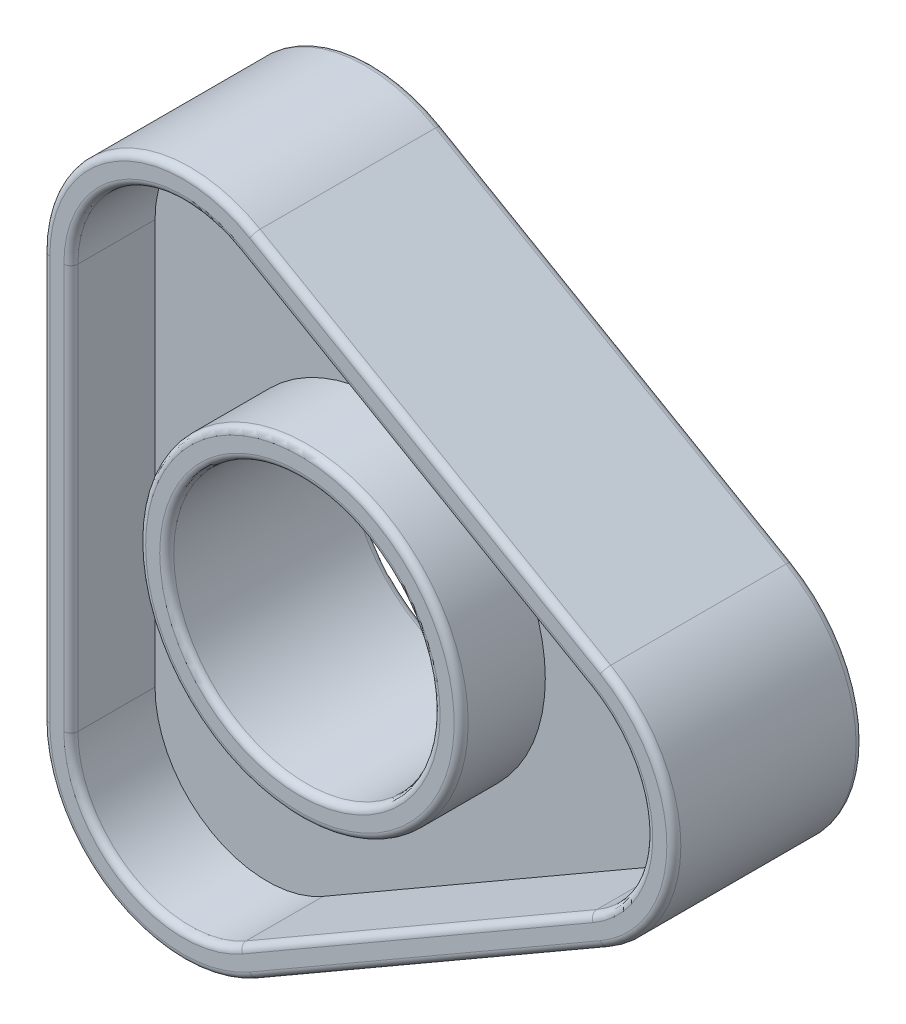
from build123d import *

# Parameters (mm, degrees)
EXTRUDE_1_DEPTH     = 13.5
CUT_EXTRUDE_1_DEPTH = 6
CUT_EXTRUDE_2_DEPTH = 6
EXTRUDE_START       = -7.5
SKETCH_4_R          = 11.5
EXTRUDE_2_DEPTH     = 13.5
CUT_EXTRUDE_3_REACH = 15.5
SKETCH_5_R          = 9.5
FILLET_1_R          = 0.5


with BuildPart() as part:
    # 草圖1 → 填料-伸長1 (new body)
    with BuildSketch(Plane.XY):
        with BuildLine():
            Line((21.666666667, 8.660254038), (-3.333333333, 23.094010768))
            ThreePointArc((-3.333333333, 23.094010768), (-13.333333333, 23.094010768), (-18.333333333, 14.43375673))
            Line((-18.333333333, 14.43375673), (-18.333333333, -14.43375673))
            ThreePointArc((-18.333333333, -14.43375673), (-13.333333333, -23.094010768), (-3.333333333, -23.094010768))
            Line((-3.333333333, -23.094010768), (21.666666667, -8.660254038))
            ThreePointArc((21.666666667, -8.660254038), (26.666666667, 0), (21.666666667, 8.660254038))
        make_face()
    extrude(amount=EXTRUDE_1_DEPTH)

    # 草圖2 → 除料-伸長1 (cut)
    with BuildSketch(Plane.XY.offset(13.5)):
        with BuildLine():
            Line((20.666666667, 6.92820323), (-4.333333333, 21.36195996))
            ThreePointArc((-4.333333333, 21.36195996), (-12.333333333, 21.36195996), (-16.333333333, 14.43375673))
            Line((-16.333333333, 14.43375673), (-16.333333333, -14.43375673))
            ThreePointArc((-16.333333333, -14.43375673), (-12.333333333, -21.36195996), (-4.333333333, -21.36195996))
            Line((-4.333333333, -21.36195996), (20.666666667, -6.92820323))
            ThreePointArc((20.666666667, -6.92820323), (24.666666667, 0), (20.666666667, 6.92820323))
        make_face()
    extrude(amount=-CUT_EXTRUDE_1_DEPTH, mode=Mode.SUBTRACT)

    # 草圖3 → 除料-伸長2 (cut)
    with BuildSketch(Plane(origin=(0, 0, 0), x_dir=(-1, 0, 0), z_dir=(0, 0, -1))):
        with BuildLine():
            Line((-20.666666667, -6.92820323), (4.333333333, -21.36195996))
            ThreePointArc((4.333333333, -21.36195996), (12.333333333, -21.36195996), (16.333333333, -14.43375673))
            Line((16.333333333, -14.43375673), (16.333333333, 14.43375673))
            ThreePointArc((16.333333333, 14.43375673), (12.333333333, 21.36195996), (4.333333333, 21.36195996))
            Line((4.333333333, 21.36195996), (-20.666666667, 6.92820323))
            ThreePointArc((-20.666666667, 6.92820323), (-24.666666667, 0), (-20.666666667, -6.92820323))
        make_face()
    extrude(amount=-CUT_EXTRUDE_2_DEPTH, mode=Mode.SUBTRACT)

    # 草圖4 → 填料-伸長2 (add)
    with BuildSketch(Plane.XY.offset(7.5).offset(EXTRUDE_START)):
        Circle(SKETCH_4_R)
    extrude(amount=EXTRUDE_2_DEPTH)

    # 草圖5 → 除料-伸長3 (cut, up to next)
    with BuildSketch(Plane.XY.offset(13.5), mode=Mode.PRIVATE) as cut_extrude_3_sk1:
        Circle(SKETCH_5_R)
    cut_extrude_3_tool1 = extrude(cut_extrude_3_sk1.sketch, amount=-CUT_EXTRUDE_3_REACH, mode=Mode.PRIVATE) & part.part
    add(cut_extrude_3_tool1.solids().sort_by_distance((0, 0, 13.5))[0], mode=Mode.SUBTRACT)

    # 圓角1
    fillet_1_edges = [part.edges().sort_by_distance(p)[0] for p in [
        (-13.333333333, 23.094010768, 13.5),
        (-18.333333333, 0, 13.5),
        (-13.333333333, -23.094010768, 13.5),
        (24.666666667, 0, 13.5),
        (9.166666667, -15.877132403, 13.5),
        (8.166666667, 14.145081595, 13.5),
        (-12.333333333, 21.36195996, 13.5),
        (-16.333333333, 0, 13.5),
        (-12.333333333, -21.36195996, 13.5),
        (8.166666667, -14.145081595, 13.5),
        (26.666666667, 0, 13.5),
        (-11.5, 0, 13.5),
        (-11.5, 0, 0),
        (-9.5, 0, 0),
        (-9.5, 0, 13.5),
        (9.166666667, -15.877132403, 0),
        (-13.333333333, -23.094010768, 0),
        (-18.333333333, 0, 0),
        (-13.333333333, 23.094010768, 0),
        (9.166666667, 15.877132403, 0),
        (26.666666667, 0, 0),
        (9.166666667, 15.877132403, 13.5),
    ]]
    fillet(fillet_1_edges, radius=FILLET_1_R)


solid = part.part
